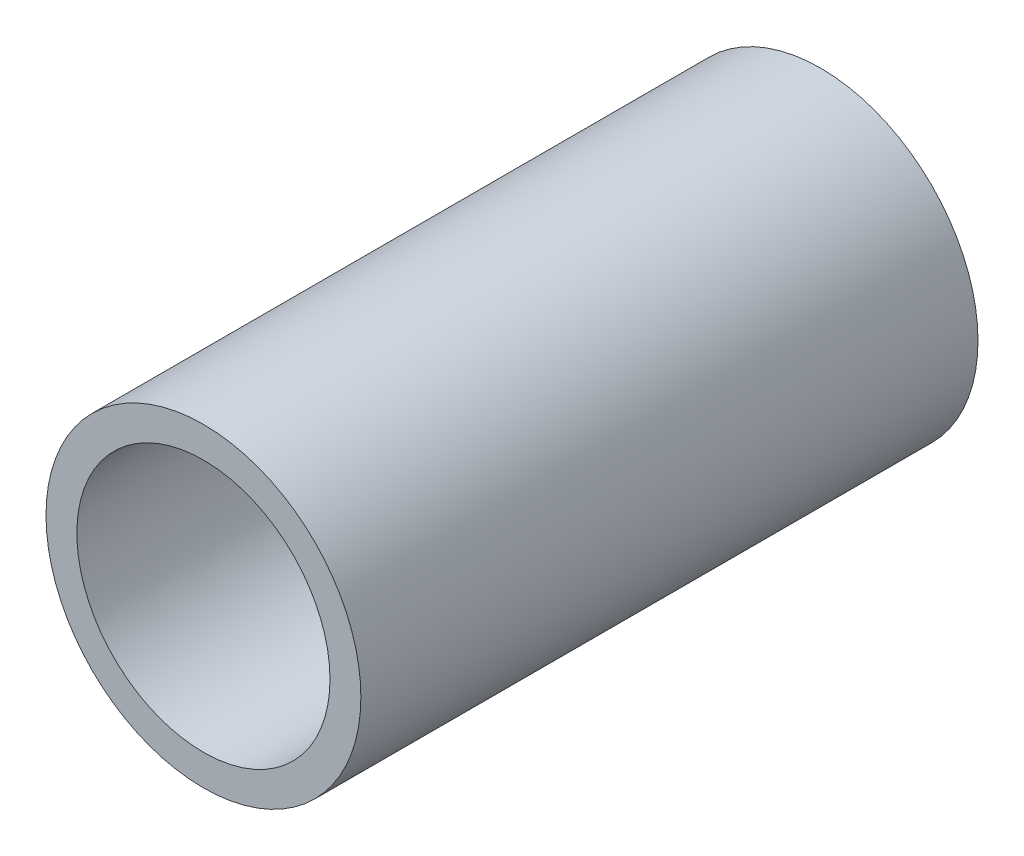
from build123d import *

# Parameters (mm, degrees)
SKETCH3_R                = 6.35
SKETCH3_R_2              = 5.1054
BOSS_EXTRUDE1_DEPTH      = 12.446
BOSS_EXTRUDE1_DEPTH_BACK = 12.446


with BuildPart() as part:
    # Sketch3 → Boss-Extrude1 (new body, two sides)
    with BuildSketch(Plane.XY) as boss_extrude1_sk:
        Circle(SKETCH3_R)
        Circle(SKETCH3_R_2, mode=Mode.SUBTRACT)
    extrude(amount=BOSS_EXTRUDE1_DEPTH)
    extrude(boss_extrude1_sk.sketch, amount=-BOSS_EXTRUDE1_DEPTH_BACK)


solid = part.part
